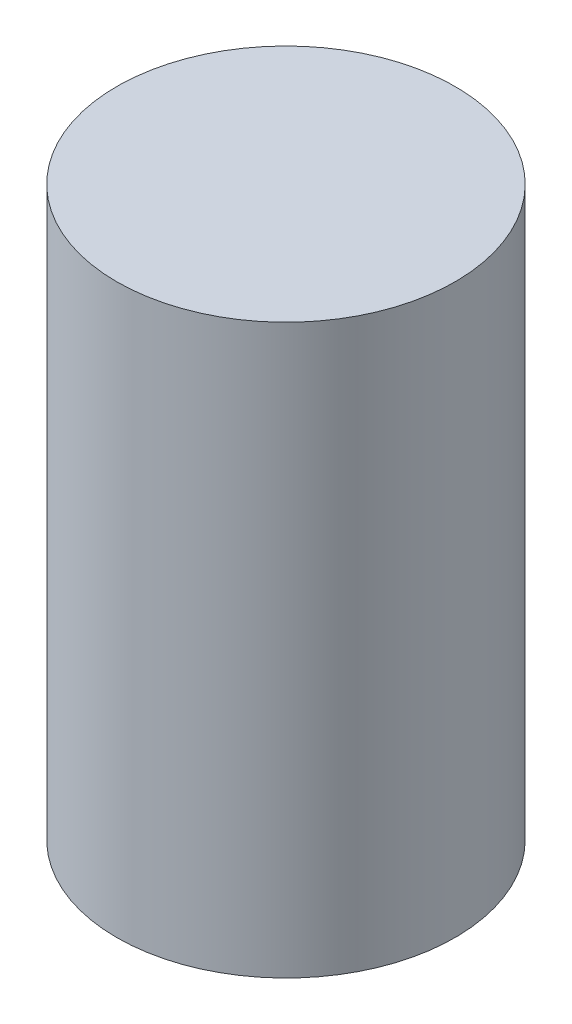
from build123d import *

# Parameters (mm, degrees)
SKETCH1_R           = 14
BOSS_EXTRUDE1_DEPTH = 23.5


with BuildPart() as part:
    # Sketch1 → Boss-Extrude1 (new body, symmetric)
    with BuildSketch(Plane(origin=(0, 0, 0), x_dir=(1, 0, 0), z_dir=(0, 1, 0))):
        Circle(SKETCH1_R)
    extrude(amount=BOSS_EXTRUDE1_DEPTH, both=True)


solid = part.part
